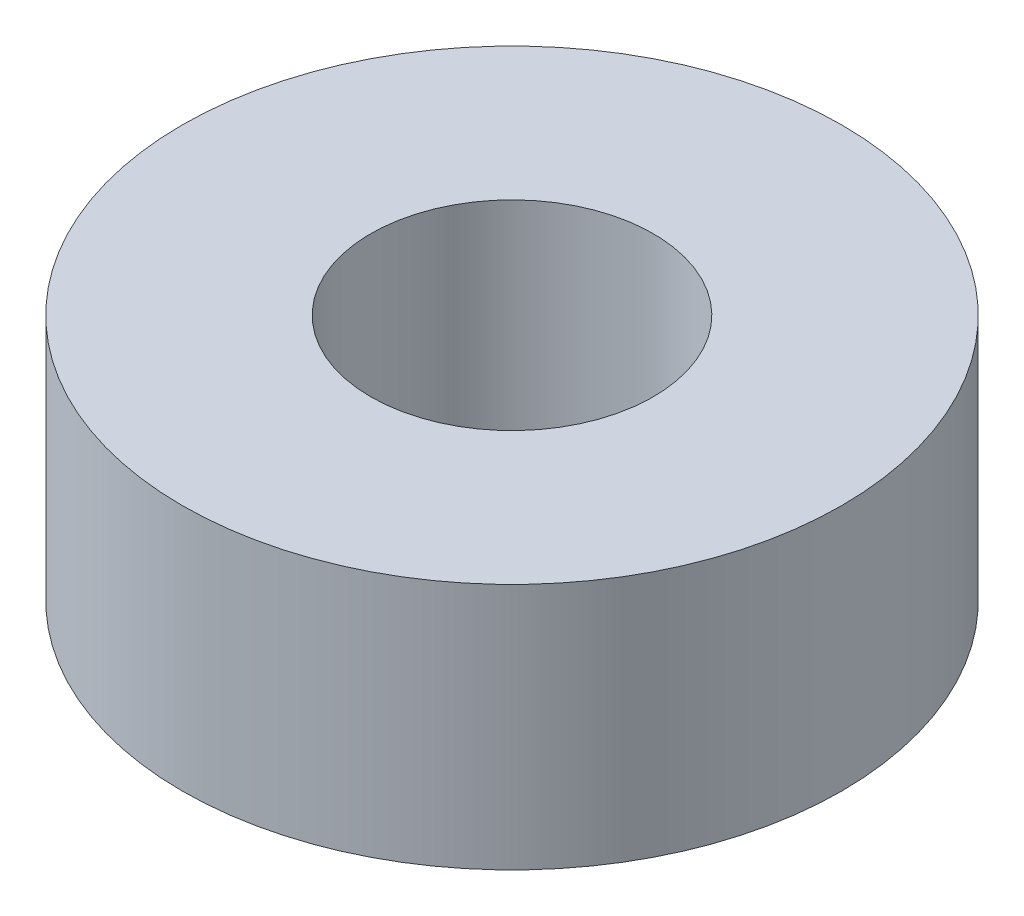
from build123d import *

# Parameters (mm, degrees)
SKETCH1_R           = 4
SKETCH1_R_2         = 1.7145
BOSS_EXTRUDE1_DEPTH = 3


with BuildPart() as part:
    # Sketch1 → Boss-Extrude1 (new body)
    with BuildSketch(Plane(origin=(0, 0, 0), x_dir=(1, 0, 0), z_dir=(0, 1, 0))):
        Circle(SKETCH1_R)
        Circle(SKETCH1_R_2, mode=Mode.SUBTRACT)
    extrude(amount=BOSS_EXTRUDE1_DEPTH)


solid = part.part
